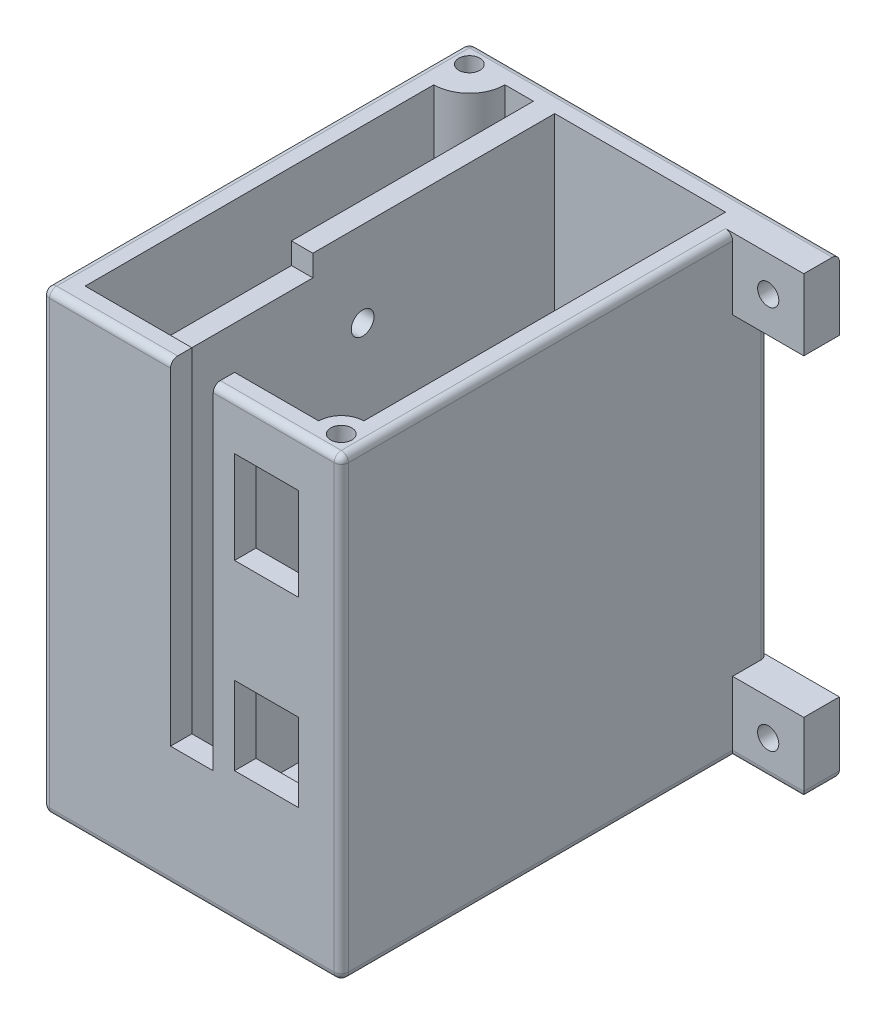
from build123d import *

# Parameters (mm, degrees)
SKETCH1_W           = 42
SKETCH1_H           = 60
BOSS_EXTRUDE1_DEPTH = 64
SKETCH2_W           = 36
SKETCH2_H           = 54
CUT_EXTRUDE1_DEPTH  = 61
SKETCH5_W           = 3
SKETCH5_H           = 54
BOSS_EXTRUDE2_DEPTH = 61
SKETCH6_W           = 6
SKETCH6_H           = 47
CUT_EXTRUDE3_DEPTH  = 3
SKETCH7_W           = 6
SKETCH7_H           = 16
CUT_EXTRUDE4_DEPTH  = 3
BOSS_EXTRUDE3_DEPTH = 64
SKETCH10_R          = 1.48
CUT_EXTRUDE6_DEPTH  = 64
BOSS_EXTRUDE4_DEPTH = 64
SKETCH12_R          = 1.48
CUT_EXTRUDE7_DEPTH  = 64
SKETCH13_W          = 5
SKETCH13_H          = 10
BOSS_EXTRUDE5_DEPTH = 10
SKETCH14_R          = 1.49
CUT_EXTRUDE8_DEPTH  = 5
SKETCH15_W          = 5
SKETCH15_H          = 10
BOSS_EXTRUDE6_DEPTH = 10
SKETCH16_R          = 1.49
CUT_EXTRUDE9_DEPTH  = 5
SKETCH17_R          = 1.6
CUT_EXTRUDE10_DEPTH = 3
FILLET1_R           = 1
SKETCH21_W          = 9
SKETCH21_H          = 13
SKETCH21_H_2        = 11
CUT_EXTRUDE11_DEPTH = 3
SKETCH23_W          = 20
SKETCH23_H          = 3
CUT_EXTRUDE12_DEPTH = 3


with BuildPart() as part:
    # Sketch1 → Boss-Extrude1 (new body)
    with BuildSketch(Plane(origin=(0, 0, 0), x_dir=(1, 0, 0), z_dir=(0, 1, 0))):
        with Locations((-528.043708609, 339.393377483)):
            Rectangle(SKETCH1_W, SKETCH1_H)
    extrude(amount=BOSS_EXTRUDE1_DEPTH)

    # Sketch2 → Cut-Extrude1 (cut)
    with BuildSketch(Plane(origin=(0, 64, 0), x_dir=(1, 0, 0), z_dir=(0, 1, 0))):
        with Locations((-528.043708609, 339.393377483)):
            Rectangle(SKETCH2_W, SKETCH2_H)
    extrude(amount=-CUT_EXTRUDE1_DEPTH, mode=Mode.SUBTRACT)

    # Sketch5 → Boss-Extrude2 (add)
    with BuildSketch(Plane(origin=(0, 3, 0), x_dir=(1, 0, 0), z_dir=(0, 1, 0))):
        with Locations((-535.543708609, 339.393377483)):
            Rectangle(SKETCH5_W, SKETCH5_H)
    extrude(amount=BOSS_EXTRUDE2_DEPTH)

    # Sketch6 → Cut-Extrude3 (cut)
    with BuildSketch(Plane(origin=(0, 0, -312.393377483), x_dir=(-1, 0, 0), z_dir=(0, 0, -1))):
        with Locations((528.043708609, 40.5)):
            Rectangle(SKETCH6_W, SKETCH6_H)
    extrude(amount=-CUT_EXTRUDE3_DEPTH, mode=Mode.SUBTRACT)

    # Sketch7 → Cut-Extrude4 (cut)
    with BuildSketch(Plane(origin=(0, 3, 0), x_dir=(1, 0, 0), z_dir=(0, 1, 0))):
        with Locations((-528.043708609, 323.393377483)):
            Rectangle(SKETCH7_W, SKETCH7_H)
    extrude(amount=-CUT_EXTRUDE4_DEPTH, mode=Mode.SUBTRACT)

    # Sketch9 → Boss-Extrude3 (add)
    with BuildSketch(Plane.XZ):
        with BuildLine():
            Line((-507.043708609, -313.393377483), (-507.043708609, -309.393377483))
            Line((-507.043708609, -309.393377483), (-511.043708609, -309.393377483))
            ThreePointArc((-511.043708609, -309.393377483), (-512.279776587, -314.629445461), (-507.043708609, -313.393377483))
        make_face()
    extrude(amount=-BOSS_EXTRUDE3_DEPTH)

    # Sketch10 → Cut-Extrude6 (cut)
    with BuildSketch(Plane(origin=(0, 0, 0), x_dir=(-1, 0, 0), z_dir=(0, -1, 0))):
        with Locations((510.043708609, 312.393377483)):
            Circle(SKETCH10_R)
    extrude(amount=-CUT_EXTRUDE6_DEPTH, mode=Mode.SUBTRACT)

    # Sketch11 → Boss-Extrude4 (add)
    with BuildSketch(Plane.XZ):
        with BuildLine():
            Line((-542.043708609, -369.393377483), (-549.043708609, -369.393377483))
            Line((-549.043708609, -369.393377483), (-549.043708609, -362.393377483))
            ThreePointArc((-549.043708609, -362.393377483), (-542.508174703, -362.857843578), (-542.043708609, -369.393377483))
        make_face()
    extrude(amount=-BOSS_EXTRUDE4_DEPTH)

    # Sketch12 → Cut-Extrude7 (cut)
    with BuildSketch(Plane(origin=(0, 0, 0), x_dir=(-1, 0, 0), z_dir=(0, -1, 0))):
        with Locations((546.043708609, 366.393377483)):
            Circle(SKETCH12_R)
    extrude(amount=-CUT_EXTRUDE7_DEPTH, mode=Mode.SUBTRACT)

    # Sketch13 → Boss-Extrude5 (add)
    with BuildSketch(Plane(origin=(-507.043708609, 0, 0), x_dir=(0, 0, -1), z_dir=(1, 0, 0))):
        with Locations((366.893377483, 59)):
            Rectangle(SKETCH13_W, SKETCH13_H)
    extrude(amount=BOSS_EXTRUDE5_DEPTH)

    # Sketch14 → Cut-Extrude8 (cut)
    with BuildSketch(Plane(origin=(0, 0, -369.393377483), x_dir=(-1, 0, 0), z_dir=(0, 0, -1))):
        with Locations((502.043708609, 59)):
            Circle(SKETCH14_R)
    extrude(amount=-CUT_EXTRUDE8_DEPTH, mode=Mode.SUBTRACT)

    # Sketch15 → Boss-Extrude6 (add)
    with BuildSketch(Plane(origin=(-507.043708609, 0, 0), x_dir=(0, 0, -1), z_dir=(1, 0, 0))):
        with Locations((366.893377483, 5)):
            Rectangle(SKETCH15_W, SKETCH15_H)
    extrude(amount=BOSS_EXTRUDE6_DEPTH)

    # Sketch16 → Cut-Extrude9 (cut)
    with BuildSketch(Plane.XY.offset(-364.393377483)):
        with Locations((-502.043708609, 5)):
            Circle(SKETCH16_R)
    extrude(amount=-CUT_EXTRUDE9_DEPTH, mode=Mode.SUBTRACT)

    # Sketch17 → Cut-Extrude10 (cut)
    with BuildSketch(Plane(origin=(-534.043708609, 0, 0), x_dir=(0, 0, -1), z_dir=(1, 0, 0))):
        with Locations((339.393377483, 52)):
            Circle(SKETCH17_R)
    extrude(amount=-CUT_EXTRUDE10_DEPTH, mode=Mode.SUBTRACT)

    # Fillet1
    fillet1_edges = [part.edges().sort_by_distance(p)[0] for p in [
        (-507.043708609, 64, -336.893377483),
        (-507.043708609, 32, -369.393377483),
        (-523.043708609, 64, -369.393377483),
        (-502.043708609, 0, -364.393377483),
        (-497.043708609, 0, -366.893377483),
        (-549.043708609, 64, -339.393377483),
        (-516.043708609, 64, -309.393377483),
        (-523.043708609, 0, -369.393377483),
        (-507.043708609, 0, -336.893377483),
        (-528.043708609, 0, -309.393377483),
        (-549.043708609, 0, -339.393377483),
        (-540.043708609, 64, -309.393377483),
        (-549.043708609, 32, -369.393377483),
        (-507.043708609, 32, -309.393377483),
        (-549.043708609, 32, -309.393377483),
    ]]
    fillet(fillet1_edges, radius=FILLET1_R)

    # Sketch21 → Cut-Extrude11 (cut)
    with BuildSketch(Plane.XY.offset(-309.393377483)):
        with Locations((-517.543708609, 50.606602204)):
            Rectangle(SKETCH21_W, SKETCH21_H)
        with Locations((-517.543708609, 24.011624804)):
            Rectangle(SKETCH21_W, SKETCH21_H_2)
    extrude(amount=-CUT_EXTRUDE11_DEPTH, mode=Mode.SUBTRACT)

    # Sketch23 → Cut-Extrude12 (cut)
    with BuildSketch(Plane(origin=(-534.043708609, 0, 0), x_dir=(0, 0, -1), z_dir=(1, 0, 0))):
        with Locations((322.393377483, 62.5)):
            Rectangle(SKETCH23_W, SKETCH23_H)
    extrude(amount=-CUT_EXTRUDE12_DEPTH, mode=Mode.SUBTRACT)


solid = part.part
